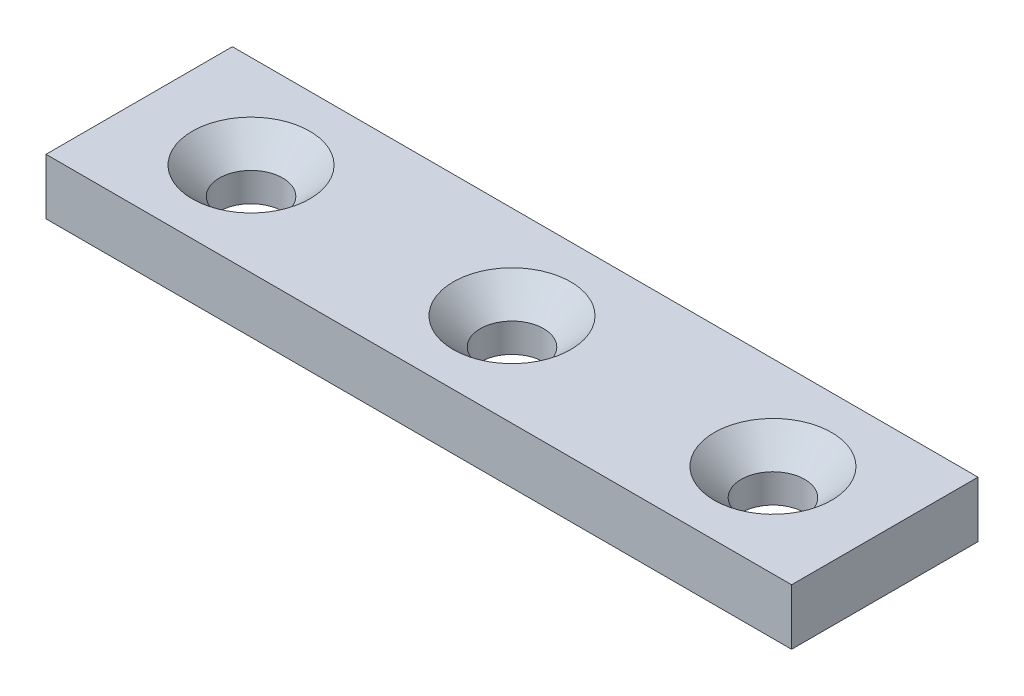
from build123d import *

# Parameters (mm, degrees)
SKETCH1_W                                    = 40
SKETCH1_H                                    = 10
BOSS_EXTRUDE1_DEPTH                          = 3
CSK_FOR_M3_COUNTERSUNK_FLAT_HEAD_SCR_2_COUNT = 2
CSK_FOR_M3_COUNTERSUNK_FLAT_HEAD_SCR_2_PITCH = 28
CSK_FOR_M3_COUNTERSUNK_FLAT_HEAD_SCR_3_COUNT = 2
CSK_FOR_M3_COUNTERSUNK_FLAT_HEAD_SCR_3_PITCH = 14


with BuildPart() as part:
    # Sketch1 → Boss-Extrude1 (new body)
    with BuildSketch(Plane(origin=(0, 0, 0), x_dir=(1, 0, 0), z_dir=(0, 1, 0))):
        Rectangle(SKETCH1_W, SKETCH1_H)
    extrude(amount=BOSS_EXTRUDE1_DEPTH)

    # Sketch3 → CSK for M3 Countersunk Flat Head Screw1 (revolve, cut)
    with BuildSketch(Plane(origin=(-14, 3, 0), x_dir=(0, 0, 1), z_dir=(1, 0, 0))):
        Polygon((0, 0), (0, 3), (1.7, 3), (1.7, 1.45), (3.15, 0), align=None)
    csk_for_m3_countersunk_flat_head_screw1 = revolve(axis=Axis((-14, 9.35, 0), (0, -1, 0)), mode=Mode.SUBTRACT)

    # CSK for M3 Countersunk Flat Head Scr 2: CSK for M3 Countersunk Flat Head Screw1 ×2
    with Locations(*[(i * CSK_FOR_M3_COUNTERSUNK_FLAT_HEAD_SCR_2_PITCH, 0, 0) for i in range(1, CSK_FOR_M3_COUNTERSUNK_FLAT_HEAD_SCR_2_COUNT)]):
        add(csk_for_m3_countersunk_flat_head_screw1, mode=Mode.SUBTRACT)

    # CSK for M3 Countersunk Flat Head Scr 3: CSK for M3 Countersunk Flat Head Screw1 ×2
    with Locations(*[(i * CSK_FOR_M3_COUNTERSUNK_FLAT_HEAD_SCR_3_PITCH, 0, 0) for i in range(1, CSK_FOR_M3_COUNTERSUNK_FLAT_HEAD_SCR_3_COUNT)]):
        add(csk_for_m3_countersunk_flat_head_screw1, mode=Mode.SUBTRACT)


solid = part.part
